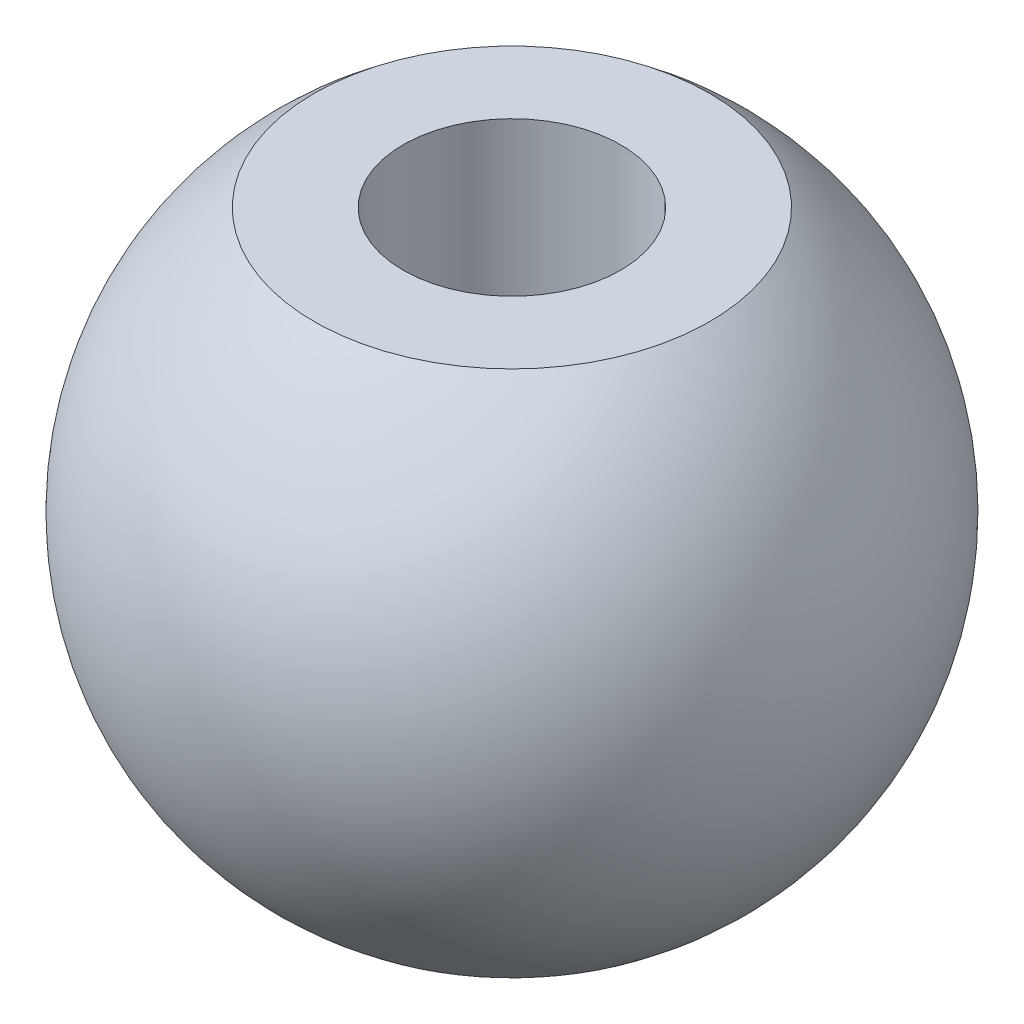
from build123d import *

# Parameters (mm, degrees)
TAP_DRILL_FOR_M4X0_7_TAP1_D     = 3.3
TAP_DRILL_FOR_M4X0_7_TAP1_DEPTH = 6
TAP_DRILL_FOR_M4X0_7_TAP1_TIP   = 0.991420021


with BuildPart() as part:
    # Sketch1 → Revolve1 (revolve)
    with BuildSketch(Plane.XY):
        with BuildLine():
            Line((0, 9), (3, 9))
            ThreePointArc((3, 9), (4.74341649, 3.41886117), (0, 0))
            Line((0, 0), (0, 9))
        make_face()
    revolve(axis=Axis((0, 0, 0), (0, 1, 0)))

    # Tap Drill for M4x0.7 Tap1
    with Locations(Plane(origin=(0, 9, 0), x_dir=(1, 0, 0), z_dir=(0, 1, 0))):
        with Locations((0, 0), (-17.99076421, 5.750523929)):
            Hole(TAP_DRILL_FOR_M4X0_7_TAP1_D / 2, depth=TAP_DRILL_FOR_M4X0_7_TAP1_DEPTH)
            with Locations((0, 0, -(TAP_DRILL_FOR_M4X0_7_TAP1_DEPTH + TAP_DRILL_FOR_M4X0_7_TAP1_TIP / 2))):  # 118° drill point
                Cone(0, TAP_DRILL_FOR_M4X0_7_TAP1_D / 2, TAP_DRILL_FOR_M4X0_7_TAP1_TIP, mode=Mode.SUBTRACT)


solid = part.part
